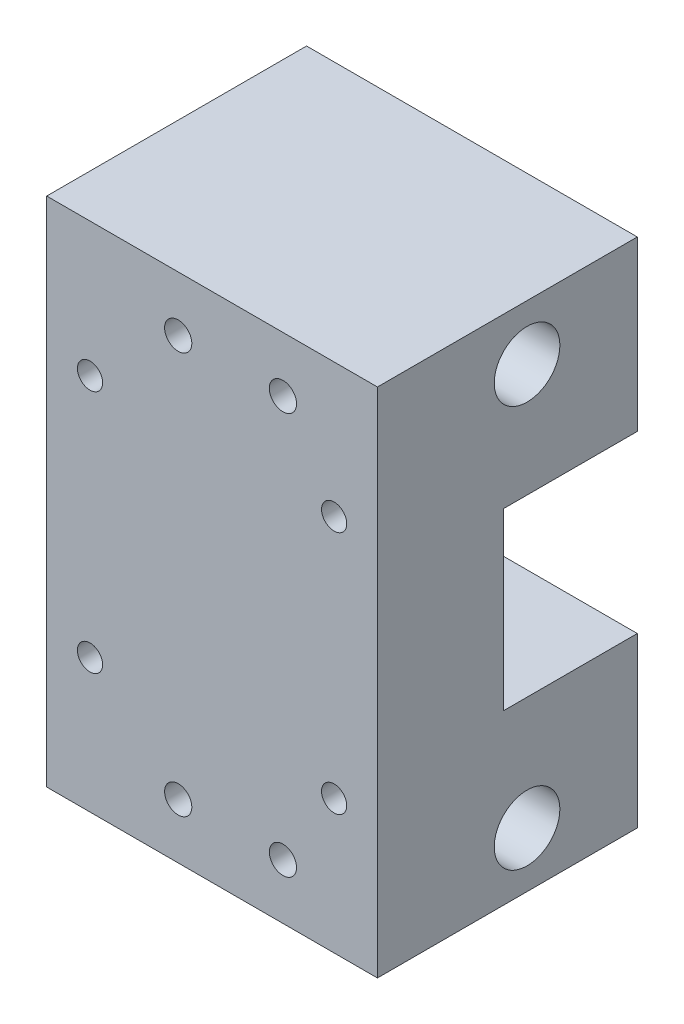
from build123d import *

# Parameters (mm, degrees)
ESBO_O1_W                                            = 42
ESBO_O1_H                                            = 65
RESSALTO_EXTRUS_O1_DEPTH                             = 21
ESBO_O2_W                                            = 17
ESBO_O2_H                                            = 22.225
CORTE_EXTRUS_O1_DEPTH                                = 43
FURO_COM_FOLGA_DE_M31_D                              = 3.4544
FURO_COM_FOLGA_DE_M31_DEPTH                          = 21
FURO_COM_FOLGA_DE_M201_D                             = 22.225
FURO_COM_FOLGA_DE_M201_DEPTH                         = 21
REBAIXO_PARA_PARAFUSO_DE_M_QUINA_DE_CABE_D           = 3.2
REBAIXO_PARA_PARAFUSO_DE_M_QUINA_DE_CABE_DEPTH       = 21
REBAIXO_PARA_PARAFUSO_DE_M_QUINA_DE_CABE_CBORE_D     = 6
REBAIXO_PARA_PARAFUSO_DE_M_QUINA_DE_CABE_CBORE_DEPTH = 7.62
FURO1_D                                              = 8.334375
FURO1_DEPTH                                          = 8
ESBO_O11_R                                           = 11.1125
ESBO_O11_R_2                                         = 5.5
RESSALTO_EXTRUS_O2_DEPTH                             = 4
ESBO_O12_W                                           = 42
ESBO_O12_H                                           = 65
ESBO_O12_R                                           = 5.5
ESBO_O12_R_2                                         = 1.6
ESBO_O12_R_3                                         = 1.7272
ESBO_O12_R_4                                         = 1.728196919
RESSALTO_EXTRUS_O3_DEPTH                             = 12
ESBO_O14_R                                           = 5.5
RESSALTO_EXTRUS_O4_DEPTH                             = 4


with BuildPart() as part:
    # Esboço1 → Ressalto-extrusão1 (new body)
    with BuildSketch(Plane.XY.offset(21)):
        with Locations((21, 32.5)):
            Rectangle(ESBO_O1_W, ESBO_O1_H)
    extrude(amount=-RESSALTO_EXTRUS_O1_DEPTH)

    # Esboço2 → Corte-extrusão1 (cut, through all)
    with BuildSketch(Plane(origin=(42, 0, 0), x_dir=(0, 0, -1), z_dir=(1, 0, 0))):
        with Locations((-8.5, 32.5)):
            Rectangle(ESBO_O2_W, ESBO_O2_H)
    extrude(amount=-CORTE_EXTRUS_O1_DEPTH, mode=Mode.SUBTRACT)

    # Furo com folga de M31
    with Locations(Plane(origin=(0, 0, 0), x_dir=(-1, 0, 0), z_dir=(0, 0, -1))):
        with Locations((-30, 7), (-16.7, 7), (-16.7, 58), (-30, 58)):
            Hole(FURO_COM_FOLGA_DE_M31_D / 2, depth=FURO_COM_FOLGA_DE_M31_DEPTH)

    # Furo com folga de M201
    with Locations(Plane.XY.offset(21)):
        with Locations((21, 32.5)):
            Hole(FURO_COM_FOLGA_DE_M201_D / 2, depth=FURO_COM_FOLGA_DE_M201_DEPTH)

    # Rebaixo para parafuso de máquina de cabeça sextavada de M31
    with Locations(Plane(origin=(0, 0, 0), x_dir=(-1, 0, 0), z_dir=(0, 0, -1))):
        with Locations((-36.5, 17), (-5.5, 17), (-5.5, 48), (-36.5, 48)):
            CounterBoreHole(REBAIXO_PARA_PARAFUSO_DE_M_QUINA_DE_CABE_D / 2, REBAIXO_PARA_PARAFUSO_DE_M_QUINA_DE_CABE_CBORE_D / 2, REBAIXO_PARA_PARAFUSO_DE_M_QUINA_DE_CABE_CBORE_DEPTH, depth=REBAIXO_PARA_PARAFUSO_DE_M_QUINA_DE_CABE_DEPTH)

    # Furo1
    with Locations(Plane(origin=(42, 0, 0), x_dir=(0, 0, -1), z_dir=(1, 0, 0))):
        with Locations((-14, 7), (-14, 58)):
            Hole(FURO1_D / 2, depth=FURO1_DEPTH)

    # Esboço11 → Ressalto-extrusão2 (add)
    with BuildSketch(Plane.XY.offset(21)):
        with Locations((21, 32.5)):
            Circle(ESBO_O11_R)
        with Locations((21, 32.5)):
            Circle(ESBO_O11_R_2, mode=Mode.SUBTRACT)
    extrude(amount=-RESSALTO_EXTRUS_O2_DEPTH)

    # Esboço12 → Ressalto-extrusão3 (add)
    with BuildSketch(Plane.XY.offset(21)):
        with Locations((21, 32.5)):
            Rectangle(ESBO_O12_W, ESBO_O12_H)
        with Locations((21, 32.5)):
            Circle(ESBO_O12_R, mode=Mode.SUBTRACT)
        with Locations((5.5, 48)):
            Circle(ESBO_O12_R_2, mode=Mode.SUBTRACT)
        with Locations((16.7, 58)):
            Circle(ESBO_O12_R_3, mode=Mode.SUBTRACT)
        with Locations((30, 58)):
            Circle(ESBO_O12_R_3, mode=Mode.SUBTRACT)
        with Locations((36.5, 48)):
            Circle(ESBO_O12_R_2, mode=Mode.SUBTRACT)
        with Locations((36.5, 17)):
            Circle(ESBO_O12_R_2, mode=Mode.SUBTRACT)
        with Locations((5.5, 17)):
            Circle(ESBO_O12_R_2, mode=Mode.SUBTRACT)
        with Locations((16.7, 7)):
            Circle(ESBO_O12_R_3, mode=Mode.SUBTRACT)
        with Locations((30, 7)):
            Circle(ESBO_O12_R_4, mode=Mode.SUBTRACT)
    extrude(amount=RESSALTO_EXTRUS_O3_DEPTH)

    # Esboço14 → Ressalto-extrusão4 (add)
    with BuildSketch(Plane.XY.offset(33)):
        with Locations((21, 32.5)):
            Circle(ESBO_O14_R)
    extrude(amount=-RESSALTO_EXTRUS_O4_DEPTH)


solid = part.part
